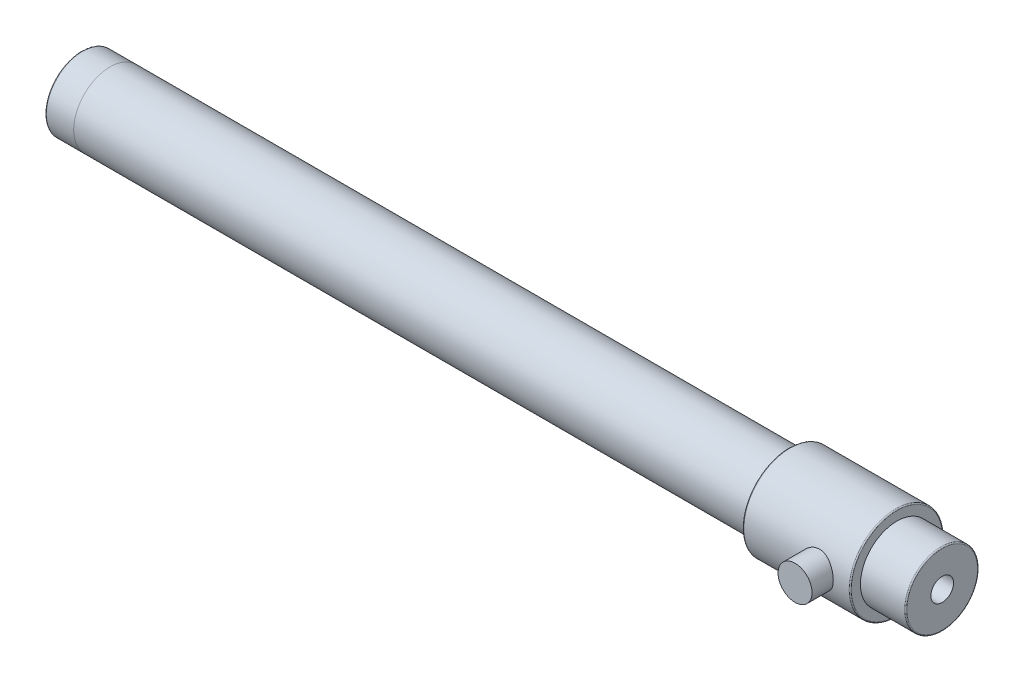
from build123d import *

# Parameters (mm, degrees)
ZAOKR_GLENIE1_R             = 0.2
SZKIC3_R                    = 3
DODANIE_WYCI_GNI_CIE1_DEPTH = 10


with BuildPart() as part:
    # Szkic1 → Obrót1 (revolve)
    with BuildSketch(Plane.XY):
        Polygon((0, 2), (152, 2), (152, 6.45), (144, 6.45), (144, 8.25), (125, 8.25), (125, 6.45), (0, 6.45), align=None)
    revolve(axis=Axis((0, 0, 0), (1, 0, 0)))

    # Zaokrąglenie1
    zaokr_glenie1_edges = [part.edges().sort_by_distance(p)[0] for p in [
        (152, -6.45, 0),
        (144, -8.25, 0),
        (125, -8.25, 0),
        (0, -6.45, 0),
    ]]
    fillet(zaokr_glenie1_edges, radius=ZAOKR_GLENIE1_R)

    # Szkic3 → Dodanie-wyciągnięcie1 (add)
    with BuildSketch(Plane(origin=(0, 0, 2), x_dir=(-1, 0, 0), z_dir=(0, 0, -1))):
        with Locations((-138, 0)):
            Circle(SZKIC3_R)
    extrude(amount=-DODANIE_WYCI_GNI_CIE1_DEPTH)


solid = part.part
